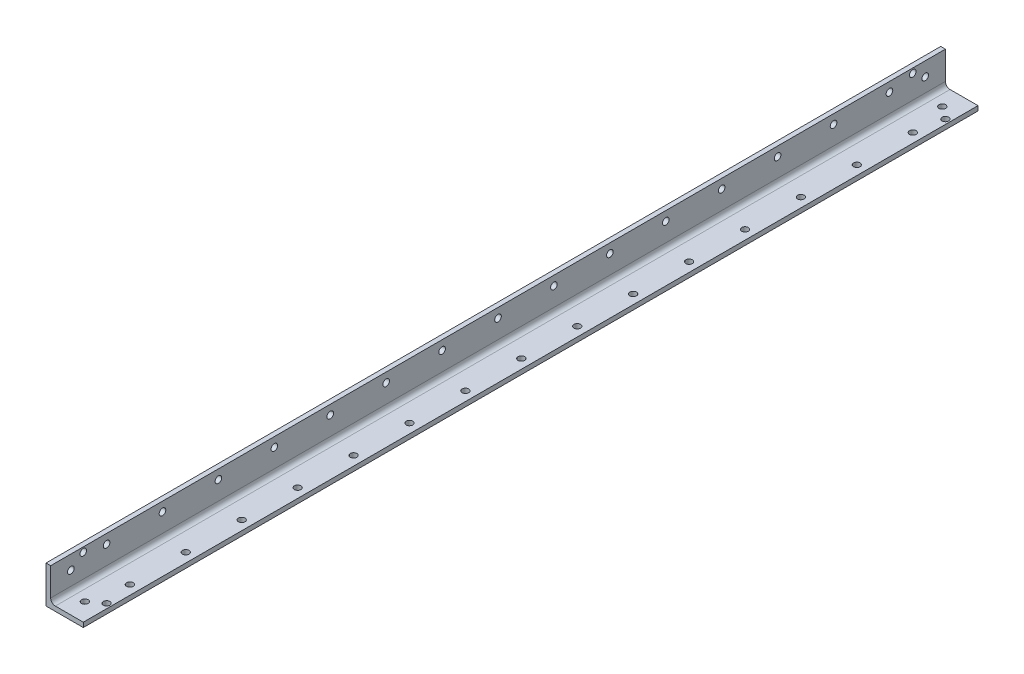
from build123d import *

# Parameters (mm, degrees)
BOSS_EXTRUDE1_DEPTH = 304.8
FILLET1_R           = 3.175
SKETCH2_R           = 2.25
CUT_EXTRUDE1_DEPTH  = 307.662926721
SKETCH2_3_R         = 2.25
CUT_EXTRUDE2_DEPTH  = 307.662926721
SKETCH3_R           = 2.25
CUT_EXTRUDE3_DEPTH  = 307.662926721


with BuildPart() as part:
    # Sketch1 → Boss-Extrude1 (new, symmetric)
    with BuildSketch(Plane.XY):
        Polygon((0, 25.4), (0, 0), (25.4, 0), (25.4, 3.175), (3.175, 3.175), (3.175, 25.4), align=None)
    extrude(amount=BOSS_EXTRUDE1_DEPTH, both=True)

    # Fillet1
    fillet1_edges = [part.edges().sort_by_distance(p)[0] for p in [
        (3.175, 3.175, 0),
    ]]
    fillet(fillet1_edges, radius=FILLET1_R)

    # Sketch2 → Cut-Extrude1 (cut, through all)
    with BuildSketch(Plane(origin=(0, 3.175, 0), x_dir=(1, 0, 0), z_dir=(0, 1, 0))):
        with Locations((22.225, 285.75)):
            Circle(SKETCH2_R)
        with Locations((13.758333333, 292.1)):
            Circle(SKETCH2_R)
        with Locations((22.225, -285.75)):
            Circle(SKETCH2_R)
        with Locations((13.758333333, -292.1)):
            Circle(SKETCH2_R)
    extrude(amount=-CUT_EXTRUDE1_DEPTH, mode=Mode.SUBTRACT)

    # Sketch2_3 → Cut-Extrude2 (cut, through all)
    with BuildSketch(Plane(origin=(0, 3.175, 0), x_dir=(1, 0, 0), z_dir=(0, 1, 0))):
        with Locations((19.05, 0)):
            Circle(SKETCH2_3_R)
        with Locations((19.05, -266.7)):
            Circle(SKETCH2_3_R)
        with Locations((19.05, -228.6)):
            Circle(SKETCH2_3_R)
        with Locations((19.05, -190.5)):
            Circle(SKETCH2_3_R)
        with Locations((19.05, -152.4)):
            Circle(SKETCH2_3_R)
        with Locations((19.05, -114.3)):
            Circle(SKETCH2_3_R)
        with Locations((19.05, -76.2)):
            Circle(SKETCH2_3_R)
        with Locations((19.05, -38.1)):
            Circle(SKETCH2_3_R)
        with Locations((19.05, 38.1)):
            Circle(SKETCH2_3_R)
        with Locations((19.05, 76.2)):
            Circle(SKETCH2_3_R)
        with Locations((19.05, 114.3)):
            Circle(SKETCH2_3_R)
        with Locations((19.05, 152.4)):
            Circle(SKETCH2_3_R)
        with Locations((19.05, 190.5)):
            Circle(SKETCH2_3_R)
        with Locations((19.05, 228.6)):
            Circle(SKETCH2_3_R)
        with Locations((19.05, 266.7)):
            Circle(SKETCH2_3_R)
    cut_extrude2 = extrude(amount=-CUT_EXTRUDE2_DEPTH, mode=Mode.SUBTRACT)

    # Mirror1: Cut-Extrude2 across plane
    add(cut_extrude2.mirror(Plane(origin=(0, 0, 0), x_dir=(0, 0, 1), z_dir=(-0.7071067811865488, 0.7071067811865464, 0))), mode=Mode.SUBTRACT)

    # Sketch3 → Cut-Extrude3 (cut, through all)
    with BuildSketch(Plane(origin=(3.175, 0, 0), x_dir=(0, 0, -1), z_dir=(1, 0, 0))):
        with Locations((-282.575, 22.225)):
            Circle(SKETCH3_R)
        with Locations((-291.041666667, 15.875)):
            Circle(SKETCH3_R)
        with Locations((291.041666667, 15.875)):
            Circle(SKETCH3_R)
        with Locations((282.575, 22.225)):
            Circle(SKETCH3_R)
    extrude(amount=-CUT_EXTRUDE3_DEPTH, mode=Mode.SUBTRACT)


solid = part.part
